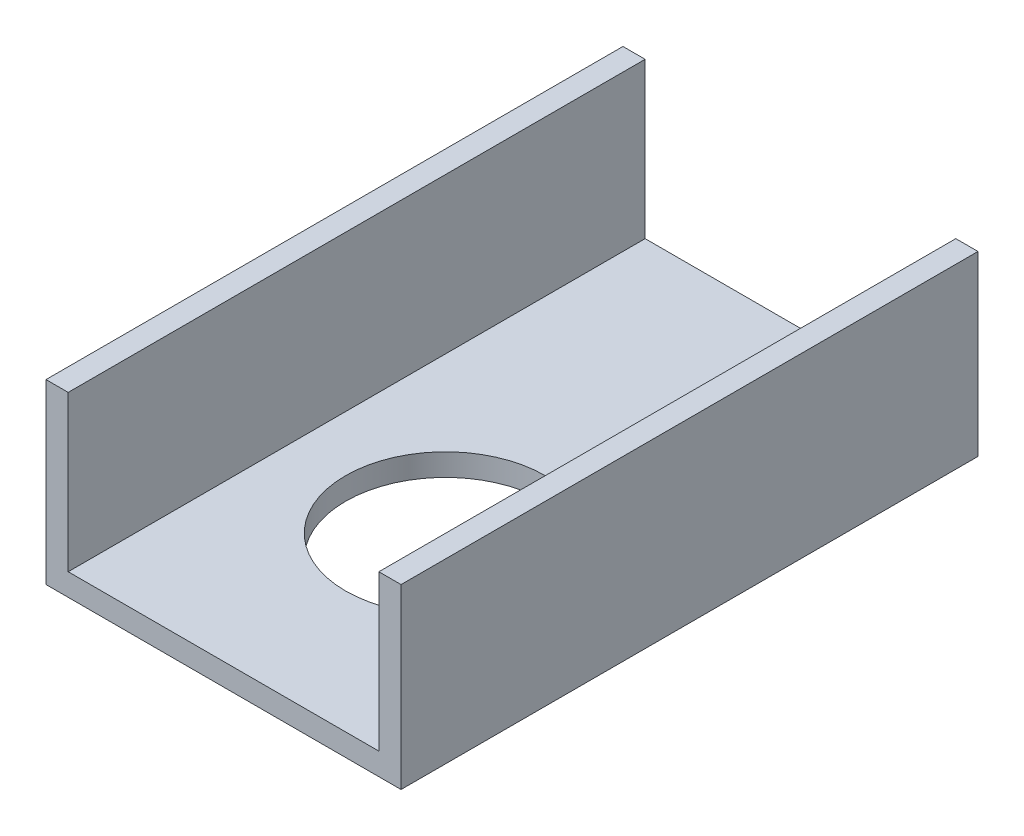
from build123d import *

# Parameters (mm, degrees)
BOSS_EXTRUDE1_DEPTH = 82.55
CUT_EXTRUDE1_REACH  = 27.4
SKETCH2_R           = 14.2875
CUT_EXTRUDE2_REACH  = 5.175
SKETCH3_W           = 3.175
SKETCH3_H           = 22.225


with BuildPart() as part:
    # Sketch1 → Boss-Extrude1 (new body)
    with BuildSketch(Plane.XY):
        Polygon((47.625, 3.175), (47.625, 25.4), (50.8, 25.4), (50.8, 0), (0, 0), (0, 25.4), (3.175, 25.4), (3.175, 3.175), align=None)
    extrude(amount=BOSS_EXTRUDE1_DEPTH)

    # Sketch2 → Cut-Extrude1 (cut, up to next)
    with BuildSketch(Plane.XZ, mode=Mode.PRIVATE) as cut_extrude1_sk1:
        with Locations((25.4, 50.8)):
            Circle(SKETCH2_R)
    cut_extrude1_tool1 = extrude(cut_extrude1_sk1.sketch, amount=-CUT_EXTRUDE1_REACH, mode=Mode.PRIVATE) & part.part
    add(cut_extrude1_tool1.solids().sort_by_distance((25.4, 0, 50.8))[0], mode=Mode.SUBTRACT)

    # Sketch3 → Cut-Extrude2 (cut, up to next)
    with BuildSketch(Plane(origin=(0, 3.175, 0), x_dir=(1, 0, 0), z_dir=(0, 1, 0)), mode=Mode.PRIVATE) as cut_extrude2_sk1:
        with Locations((46.0375, -11.1125)):
            Rectangle(SKETCH3_W, SKETCH3_H)
    cut_extrude2_tool1 = extrude(cut_extrude2_sk1.sketch, amount=-CUT_EXTRUDE2_REACH, mode=Mode.PRIVATE) & part.part
    add(cut_extrude2_tool1.solids().sort_by_distance((46.0375, 3.175, 11.1125))[0], mode=Mode.SUBTRACT)


solid = part.part
